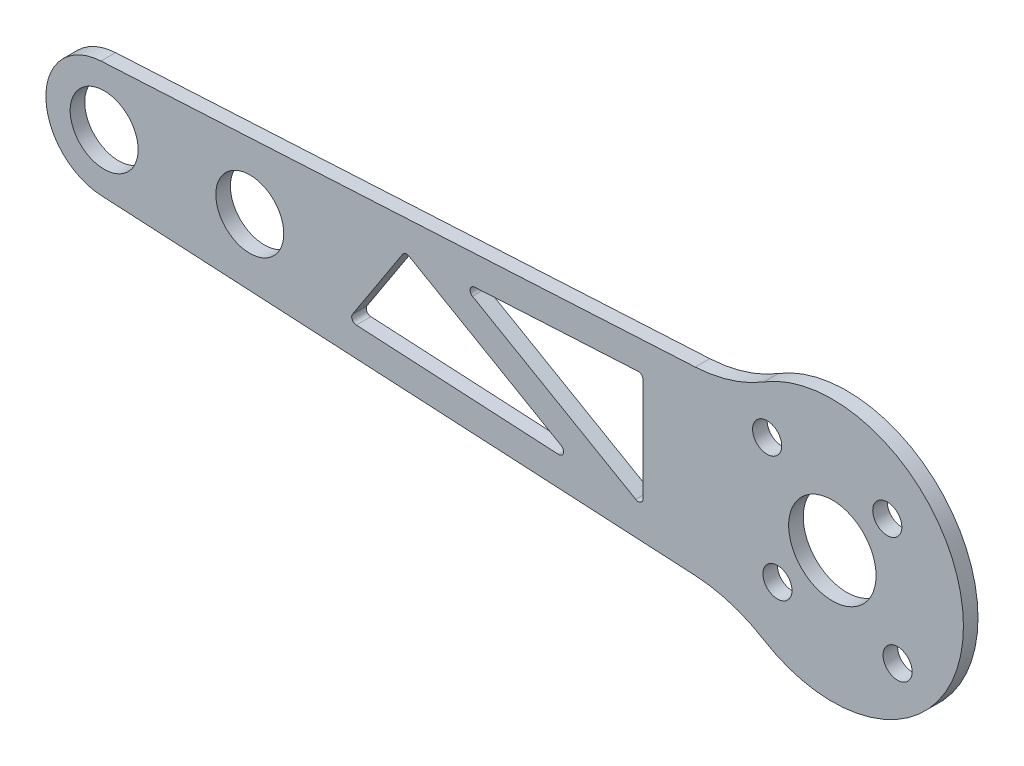
from build123d import *

# Parameters (mm, degrees)
SKETCH_1_R      = 1.5
SKETCH_1_R_2    = 4.5
SKETCH_1_R_3    = 3.5
EXTRUDE_1_DEPTH = 1.5


with BuildPart() as part:
    # 草图1 → 凸台-拉伸1 (new body)
    with BuildSketch(Plane.XY):
        with BuildLine():
            Line((-14.119787017, 9.298767484), (-75.323772101, 5.991257934))
            ThreePointArc((-75.323772101, 5.991257934), (-81, 0), (-75.323772101, -5.991257934))
            Line((-75.323772101, -5.991257934), (-14.119787017, -9.298767484))
            ThreePointArc((-14.119787017, -9.298767484), (-10.458227409, -9.958733326), (-7.071734496, -11.499590046))
            ThreePointArc((-7.071734496, -11.499590046), (13.5, 0), (-7.071734496, 11.499590046))
            ThreePointArc((-7.071734496, 11.499590046), (-10.458227409, 9.958733326), (-14.119787017, 9.298767484))
        make_face()
        with Locations((-5.656854249, -5.656854249)):
            Circle(SKETCH_1_R, mode=Mode.SUBTRACT)
        with Locations((-6.717514421, 6.717514421)):
            Circle(SKETCH_1_R, mode=Mode.SUBTRACT)
        with Locations((5.656854249, 5.656854249)):
            Circle(SKETCH_1_R, mode=Mode.SUBTRACT)
        with Locations((6.717514421, -6.717514421)):
            Circle(SKETCH_1_R, mode=Mode.SUBTRACT)
        Circle(SKETCH_1_R_2, mode=Mode.SUBTRACT)
        with Locations((-60, 0)):
            Circle(SKETCH_1_R_3, mode=Mode.SUBTRACT)
        with Locations((-75, 0)):
            Circle(SKETCH_1_R_3, mode=Mode.SUBTRACT)
        with BuildLine():
            Line((-19.5, 5.475889357), (-19.5, -5.137613899))
            ThreePointArc((-19.5, -5.137613899), (-19.75, -5.570626601), (-20.25, -5.570626601))
            Line((-20.25, -5.570626601), (-37.059715141, 4.134466961))
            ThreePointArc((-37.059715141, 4.134466961), (-37.295994973, 4.683806463), (-36.836696149, 5.066751157))
            Line((-36.836696149, 5.066751157), (-20.026981008, 5.975160851))
            ThreePointArc((-20.026981008, 5.975160851), (-19.656118119, 5.838856645), (-19.5, 5.475889357))
        make_face(mode=Mode.SUBTRACT)
        with BuildLine():
            Line((-43.593398767, 4.442589346), (-27.929722665, -4.600838268))
            ThreePointArc((-27.929722665, -4.600838268), (-27.700428576, -5.176248922), (-28.206703673, -5.533122464))
            Line((-28.206703673, -5.533122464), (-49.030790414, -4.407773099))
            ThreePointArc((-49.030790414, -4.407773099), (-49.449681707, -4.134771113), (-49.422700699, -3.635499618))
            Line((-49.422700699, -3.635499618), (-44.262290061, 4.28257863))
            ThreePointArc((-44.262290061, 4.28257863), (-43.959725568, 4.495856477), (-43.593398767, 4.442589346))
        make_face(mode=Mode.SUBTRACT)
    extrude(amount=EXTRUDE_1_DEPTH)


solid = part.part
